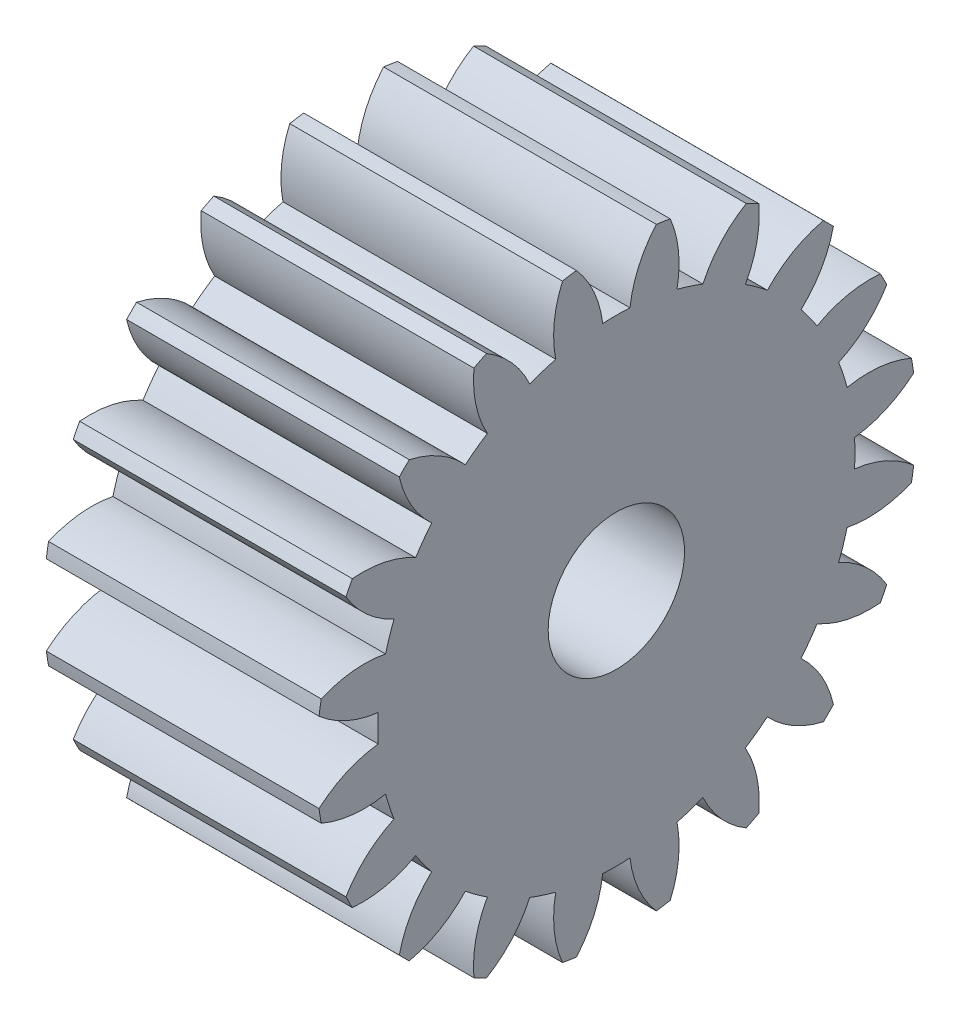
from build123d import *

# Parameters (mm, degrees)
BASPROSKE_W     = 10
BASPROSKE_H     = 11
TOOTHCUT_DEPTH  = 19.493242009
TEETHCUTS_COUNT = 20
TEETHCUTS_ANGLE = 342
BORSKE_R        = 2.5
BORE_DEPTH      = 50.0000508


with BuildPart() as part:
    # BasProSke → Base-Revolve (revolve)
    with BuildSketch(Plane(origin=(0, 0, 0), x_dir=(1, 0, 0), z_dir=(0, 1, 0)), mode=Mode.PRIVATE) as base_revolve_sk:
        with Locations((5, 5.5)):
            Rectangle(BASPROSKE_W, BASPROSKE_H)
    revolve(base_revolve_sk.sketch.rotate(Axis((-10, 0, 0), (1, 0, 0)), 180), axis=Axis((-10, 0, 0), (1, 0, 0)))

    # TooCutSke → ToothCut (cut, through all)
    with BuildSketch(Plane(origin=(0, 0, 0), x_dir=(0, 0, -1), z_dir=(1, 0, 0))):
        with BuildLine():
            ThreePointArc((0.499924007, 8.734705318), (0, 8.749), (-0.499924007, 8.734705318))
            ThreePointArc((-0.499924007, 8.734705318), (-0.824302243, 9.905497836), (-1.485192705, 10.924909509))
            ThreePointArc((-1.485192705, 10.924909509), (0, 11.0254), (1.485192705, 10.924909509))
            ThreePointArc((1.485192705, 10.924909509), (0.824302243, 9.905497836), (0.499924007, 8.734705318))
        make_face()
    toothcut = extrude(amount=TOOTHCUT_DEPTH, mode=Mode.SUBTRACT)

    # TeethCuts: ToothCut ×20 about axis
    teethcuts_axis = Axis((-10, 0, 0), (1, 0, 0))
    for i in range(1, TEETHCUTS_COUNT):
        add(toothcut.rotate(teethcuts_axis, i * TEETHCUTS_ANGLE / (TEETHCUTS_COUNT - 1)), mode=Mode.SUBTRACT)

    # BorSke → Bore (cut, symmetric)
    with BuildSketch(Plane(origin=(0, 0, 0), x_dir=(0, 0, -1), z_dir=(1, 0, 0))):
        with Locations(Location((0, 0, 0), (0, 0, 180))):
            Circle(BORSKE_R)
    extrude(amount=BORE_DEPTH, both=True, mode=Mode.SUBTRACT)


solid = part.part
